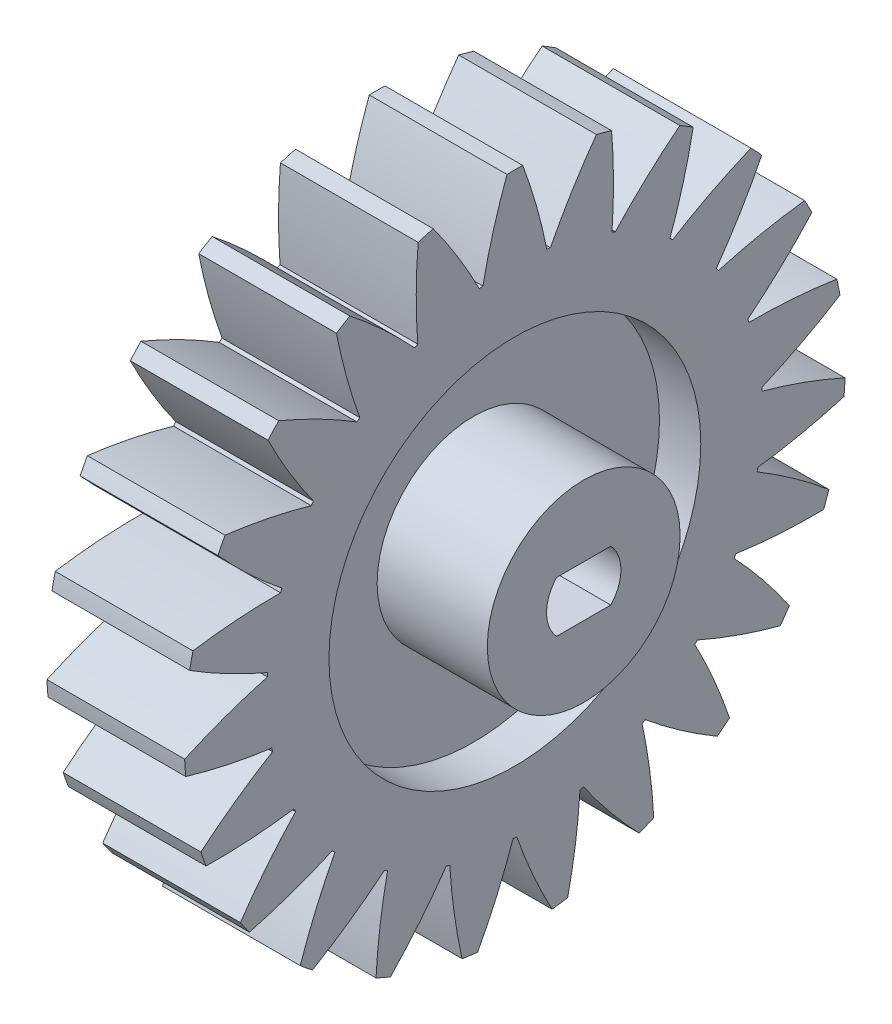
from build123d import *

# Parameters (mm, degrees)
REVOLVE_1_ANGLE          = 360
EXTRUDE_1_DEPTH          = 10
PATTERN_CIRCULAR_1_COUNT = 23
SKETCH_6_R               = 7
EXTRUDE_2_DEPTH          = 5
CUT_EXTRUDE_2_DEPTH      = 16


with BuildPart() as part:
    # 스케치3 → 회전1 (revolve, symmetric)
    with BuildSketch(Plane.XY) as revolve_1_sk:
        Polygon((-5, 18), (5, 18), (5, 13.5), (2, 13.5), (2, 7), (5, 7), (5, 0), (-5, 0), (-5, 7), (-2, 7), (-2, 13.5), (-5, 13.5), align=None)
    revolve(axis=Axis((-44.782034346, 0, 0), (1, 0, 0)), revolution_arc=REVOLVE_1_ANGLE / 2)
    revolve(revolve_1_sk.sketch, axis=Axis((-44.782034346, 0, 0), (-1, 0, 0)), revolution_arc=REVOLVE_1_ANGLE / 2)

    # 스케치4 → 보스-돌출1 (add, through all)
    with BuildSketch(Plane(origin=(5, 0, 0), x_dir=(0, 0, -1), z_dir=(1, 0, 0))):
        with BuildLine():
            ThreePointArc((0.57, 23.993230295), (0, 24), (-0.57, 23.993230295))
            Line((-0.57, 23.993230295), (-0.57, 17.990972736))
            ThreePointArc((-0.57, 17.990972736), (0.877839967, 17.978581618), (2.32, 17.849862745))
            ThreePointArc((2.32, 17.849862745), (1.565807025, 20.955959615), (0.57, 23.993230295))
        make_face()
        with BuildLine():
            Line((-0.57, 17.990972736), (-0.57, 23.993230295))
            ThreePointArc((-0.57, 23.993230295), (-1.565807025, 20.955959615), (-2.32, 17.849862745))
            ThreePointArc((-2.32, 17.849862745), (-1.446721469, 17.94176683), (-0.57, 17.990972736))
        make_face()
    extrude_1 = extrude(amount=-EXTRUDE_1_DEPTH)

    # 원형 패턴1: 보스-돌출1 ×23 about axis
    pattern_circular_1_axis = Axis((0, 0, 0), (1, 0, 0))
    for i in range(1, PATTERN_CIRCULAR_1_COUNT):
        add(extrude_1.rotate(pattern_circular_1_axis, i * 360 / PATTERN_CIRCULAR_1_COUNT))

    # 스케치6 → 보스-돌출2 (add)
    with BuildSketch(Plane(origin=(5, 0, 0), x_dir=(0, 0, -1), z_dir=(1, 0, 0))):
        Circle(SKETCH_6_R)
    extrude(amount=EXTRUDE_2_DEPTH)

    # 스케치7 → 컷-돌출2 (cut, through all)
    with BuildSketch(Plane.ZY.offset(5)):
        with BuildLine():
            Line((1.966596044, -1.85), (-1.966596044, -1.85))
            ThreePointArc((-1.966596044, -1.85), (-2.7, 0), (-1.966596044, 1.85))
            Line((-1.966596044, 1.85), (1.966596044, 1.85))
            ThreePointArc((1.966596044, 1.85), (2.7, 0), (1.966596044, -1.85))
        make_face()
    extrude(amount=-CUT_EXTRUDE_2_DEPTH, mode=Mode.SUBTRACT)


solid = part.part
